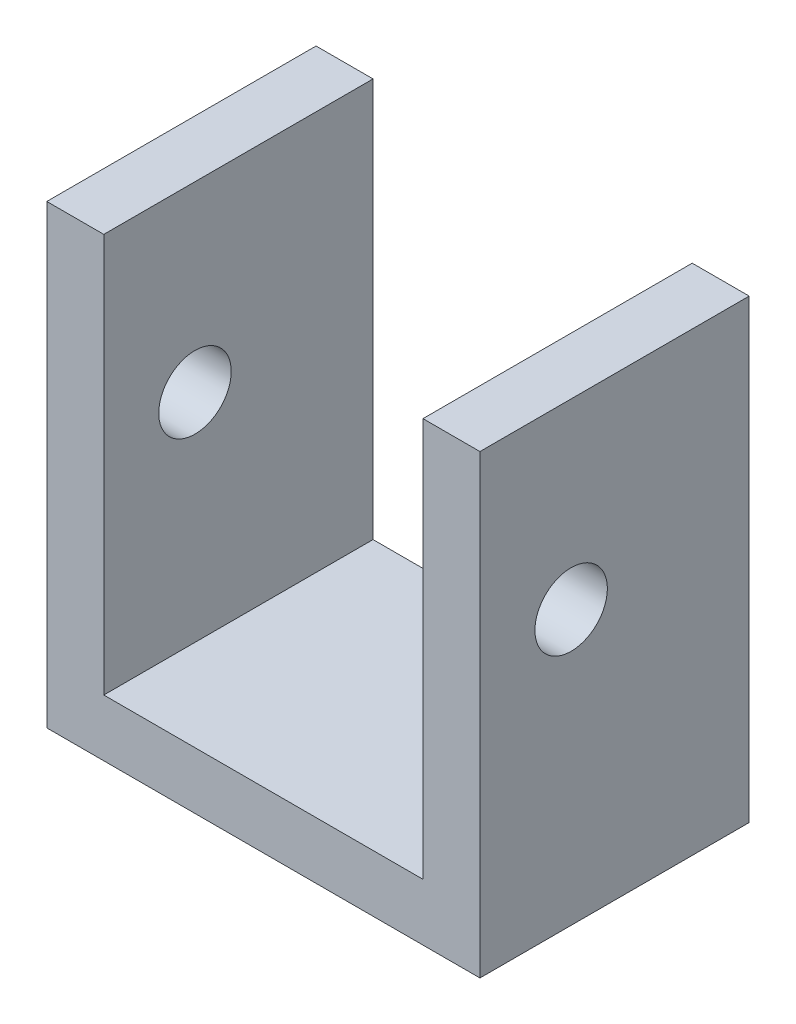
from build123d import *

# Parameters (mm, degrees)
BOSS_EXTRUDE1_DEPTH    = 15
F_10_32_TAPPED_HOLE1_D = 4.0386


with BuildPart() as part:
    # Sketch1 → Boss-Extrude1 (new body)
    with BuildSketch(Plane.XY):
        Polygon((-8.89, 25.4), (-12.065, 25.4), (-12.065, 0), (12.065, 0), (12.065, 25.4), (8.89, 25.4), (8.89, 3.175), (-8.89, 3.175), align=None)
    extrude(amount=BOSS_EXTRUDE1_DEPTH)

    # #10-32 Tapped Hole1 (through all)
    with Locations(Plane(origin=(12.065, 0, 0), x_dir=(0, 0, -1), z_dir=(1, 0, 0))):
        with Locations((-9.92, 15.24)):
            Hole(F_10_32_TAPPED_HOLE1_D / 2)


solid = part.part
